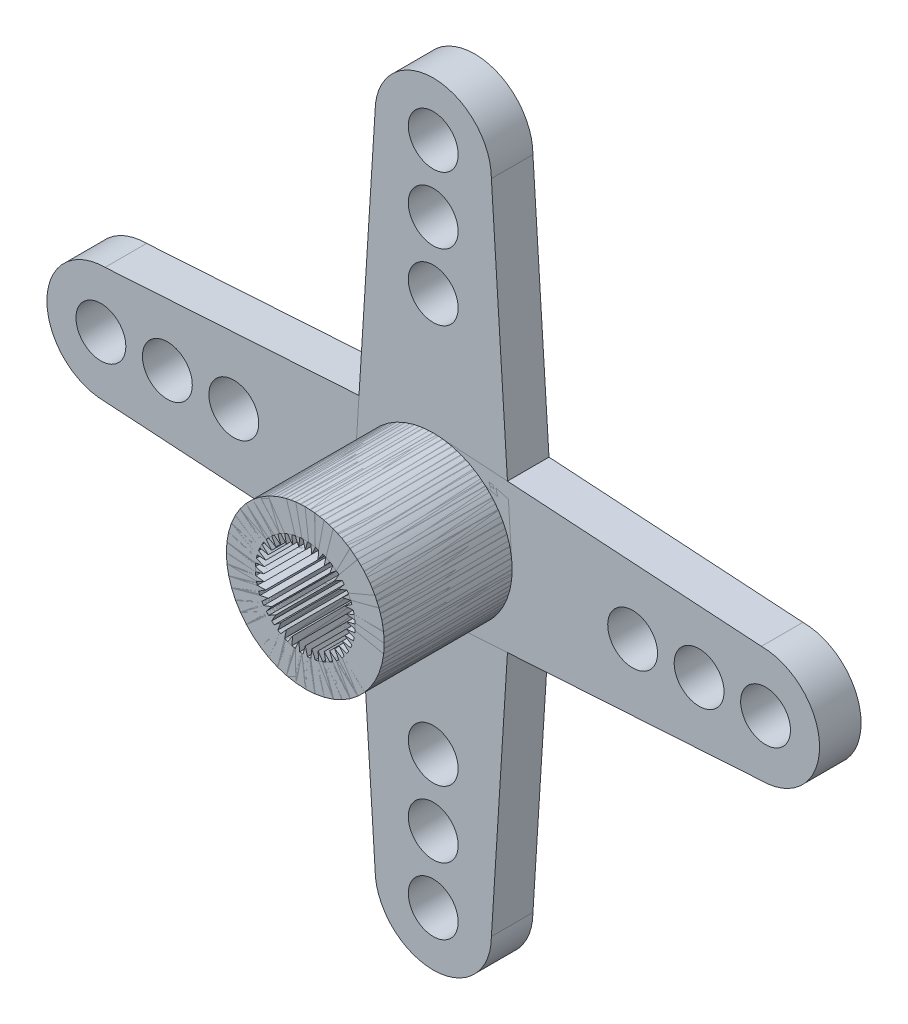
from build123d import *

# Parameters (mm, degrees)
SKETCH2_R           = 12.25
SKETCH2_R_2         = 1.594439563
BOSS_EXTRUDE1_DEPTH = 1
SKETCH3_R           = 1.5
CUT_EXTRUDE1_DEPTH  = 2
SKETCH4_R           = 4
SKETCH4_R_2         = 3
BOSS_EXTRUDE2_DEPTH = 5.7
BOSS_EXTRUDE3_START = 1
BOSS_EXTRUDE3_DEPTH = 5.7
SKETCH5_R           = 3
CUT_EXTRUDE2_DEPTH  = 0.5
SKETCH6_R           = 12.25
SKETCH6_R_2         = 4.25
CUT_EXTRUDE3_DEPTH  = 10
SKETCH7_R           = 4.25
SKETCH7_R_2         = 4
BOSS_EXTRUDE5_DEPTH = 5.7
SKETCH8_R           = 4.75
SKETCH8_R_2         = 4.25
BOSS_EXTRUDE6_DEPTH = 6.7
SKETCH9_R           = 4.75
SKETCH9_R_2         = 3
BOSS_EXTRUDE7_DEPTH = 3.5
SKETCH11_R          = 1.5
BOSS_EXTRUDE8_DEPTH = 2.5
CHAMFER3_SIZE       = 0.5
CIRPATTERN2_COUNT   = 4


with BuildPart() as part:
    # Sketch2 → Boss-Extrude1 (new body)
    with BuildSketch(Plane.XY):
        Circle(SKETCH2_R)
        with Locations((0, 8.25)):
            Circle(SKETCH2_R_2, mode=Mode.SUBTRACT)
        with Locations((0, -8.25)):
            Circle(SKETCH2_R_2, mode=Mode.SUBTRACT)
        with Locations((-8.25, 0)):
            Circle(SKETCH2_R_2, mode=Mode.SUBTRACT)
        with Locations((8.25, 0)):
            Circle(SKETCH2_R_2, mode=Mode.SUBTRACT)
    extrude(amount=BOSS_EXTRUDE1_DEPTH)

    # Sketch3 → Cut-Extrude1 (cut)
    with BuildSketch(Plane.XY.offset(1)):
        Circle(SKETCH3_R)
    extrude(amount=-CUT_EXTRUDE1_DEPTH, mode=Mode.SUBTRACT)

    # Sketch4 → Boss-Extrude2 (add)
    with BuildSketch(Plane.XY.offset(1)):
        Circle(SKETCH4_R)
        Circle(SKETCH4_R_2, mode=Mode.SUBTRACT)
    extrude(amount=BOSS_EXTRUDE2_DEPTH)

    # Sketch1 → Boss-Extrude3 (add)
    with BuildSketch(Plane.XY.offset(BOSS_EXTRUDE3_START)):
        with BuildLine():
            Line((-2.5, 0), (-2.996937116, 0.135528304))
            ThreePointArc((-2.996937116, 0.135528304), (-3, 0), (-2.996937116, -0.135528304))
            Line((-2.996937116, -0.135528304), (-2.5, 0))
        make_face()
        with BuildLine():
            Line((-2.469220853, 0.391086156), (-2.938838551, 0.602683972))
            ThreePointArc((-2.938838551, 0.602683972), (-2.963065023, 0.469303387), (-2.981241146, 0.33496452))
            Line((-2.981241146, 0.33496452), (-2.469220853, 0.391086156))
        make_face()
        with BuildLine():
            ThreePointArc((-2.808376064, 1.05499947), (-2.853169584, 0.927050875), (-2.892137153, 0.797209313))
            Line((-2.892137153, 0.797209313), (-2.37764132, 0.772542395))
            Line((-2.37764132, 0.772542395), (-2.808376064, 1.05499947))
        make_face()
        with BuildLine():
            ThreePointArc((-2.60876198, 1.481337548), (-2.673019591, 1.361971464), (-2.731819102, 1.239824339))
            Line((-2.731819102, 1.239824339), (-2.227516326, 1.13497622))
            Line((-2.227516326, 1.13497622), (-2.60876198, 1.481337548))
        make_face()
        with BuildLine():
            ThreePointArc((-2.344911528, 1.87120013), (-2.427050991, 1.763355746), (-2.504234604, 1.651910726))
            Line((-2.504234604, 1.651910726), (-2.022542492, 1.469463122))
            Line((-2.022542492, 1.469463122), (-2.344911528, 1.87120013))
        make_face()
        with BuildLine():
            ThreePointArc((-2.023321594, 2.214987523), (-2.121320362, 2.121320325), (-2.214987558, 2.023321555))
            Line((-2.214987558, 2.023321555), (-1.767766968, 1.767766938))
            Line((-1.767766968, 1.767766938), (-2.023321594, 2.214987523))
        make_face()
        with BuildLine():
            ThreePointArc((-1.651910742, 2.504234594), (-1.763355761, 2.42705098), (-1.871200145, 2.344911516))
            Line((-1.871200145, 2.344911516), (-1.469463134, 2.022542483))
            Line((-1.469463134, 2.022542483), (-1.651910742, 2.504234594))
        make_face()
        with BuildLine():
            ThreePointArc((-1.239824372, 2.731819088), (-1.361971495, 2.673019575), (-1.481337579, 2.608761963))
            Line((-1.481337579, 2.608761963), (-1.134976246, 2.227516312))
            Line((-1.134976246, 2.227516312), (-1.239824372, 2.731819088))
        make_face()
        with BuildLine():
            ThreePointArc((-0.797209399, 2.892137129), (-0.92705096, 2.853169556), (-1.054999554, 2.808376033))
            Line((-1.054999554, 2.808376033), (-0.772542467, 2.377641297))
            Line((-0.772542467, 2.377641297), (-0.797209399, 2.892137129))
        make_face()
        with BuildLine():
            ThreePointArc((-0.334964528, 2.981241145), (-0.469303394, 2.963065022), (-0.60268398, 2.938838549))
            Line((-0.60268398, 2.93883855), (-0.391086162, 2.469220852))
            Line((-0.391086162, 2.469220852), (-0.334964528, 2.981241145))
        make_face()
        with BuildLine():
            ThreePointArc((0.135528304, 2.996937116), (0, 3), (-0.135528304, 2.996937116))
            Line((-0.135528304, 2.996937116), (0, 2.5))
            Line((0, 2.5), (0.135528304, 2.996937116))
        make_face()
        with BuildLine():
            ThreePointArc((0.602683972, 2.938838551), (0.469303387, 2.963065023), (0.33496452, 2.981241146))
            Line((0.33496452, 2.981241146), (0.391086156, 2.469220853))
            Line((0.391086156, 2.469220853), (0.602683972, 2.938838551))
        make_face()
        with BuildLine():
            ThreePointArc((1.05499947, 2.808376064), (0.927050875, 2.853169584), (0.797209313, 2.892137153))
            Line((0.797209313, 2.892137153), (0.772542395, 2.37764132))
            Line((0.772542395, 2.37764132), (1.05499947, 2.808376064))
        make_face()
        with BuildLine():
            ThreePointArc((1.481337548, 2.60876198), (1.361971464, 2.673019591), (1.239824339, 2.731819102))
            Line((1.239824339, 2.731819102), (1.13497622, 2.227516326))
            Line((1.13497622, 2.227516326), (1.481337548, 2.60876198))
        make_face()
        with BuildLine():
            ThreePointArc((1.87120013, 2.344911528), (1.763355746, 2.427050991), (1.651910726, 2.504234604))
            Line((1.651910726, 2.504234604), (1.469463122, 2.022542492))
            Line((1.469463122, 2.022542492), (1.87120013, 2.344911528))
        make_face()
        with BuildLine():
            ThreePointArc((2.214987523, 2.023321594), (2.121320325, 2.121320362), (2.023321555, 2.214987558))
            Line((2.023321555, 2.214987558), (1.767766938, 1.767766968))
            Line((1.767766938, 1.767766968), (2.214987523, 2.023321594))
        make_face()
        with BuildLine():
            ThreePointArc((2.504234594, 1.651910742), (2.42705098, 1.763355761), (2.344911516, 1.871200144))
            Line((2.344911516, 1.871200145), (2.022542483, 1.469463134))
            Line((2.022542483, 1.469463134), (2.504234594, 1.651910742))
        make_face()
        with BuildLine():
            ThreePointArc((2.731819087, 1.239824371), (2.673019574, 1.361971495), (2.608761963, 1.481337578))
            Line((2.608761963, 1.481337579), (2.227516312, 1.134976246))
            Line((2.227516312, 1.134976246), (2.731819088, 1.239824371))
        make_face()
        with BuildLine():
            ThreePointArc((2.892137129, 0.797209399), (2.853169556, 0.92705096), (2.808376032, 1.054999554))
            Line((2.808376033, 1.054999554), (2.377641297, 0.772542467))
            Line((2.377641297, 0.772542467), (2.892137129, 0.797209399))
        make_face()
        with BuildLine():
            ThreePointArc((2.981241145, 0.334964528), (2.963065022, 0.469303394), (2.938838549, 0.60268398))
            Line((2.93883855, 0.60268398), (2.469220852, 0.391086162))
            Line((2.469220852, 0.391086162), (2.981241145, 0.334964528))
        make_face()
        with BuildLine():
            ThreePointArc((3, 0), (2.999234181, 0.067781455), (2.996937116, 0.135528304))
            Line((2.996937116, 0.135528304), (2.5, 0))
            Line((2.5, 0), (2.996937116, -0.135528304))
            ThreePointArc((2.996937116, -0.135528304), (2.999234181, -0.067781455), (3, 0))
        make_face()
        with BuildLine():
            ThreePointArc((2.938838551, -0.602683972), (2.963065023, -0.469303387), (2.981241146, -0.33496452))
            Line((2.981241146, -0.33496452), (2.469220853, -0.391086156))
            Line((2.469220853, -0.391086156), (2.938838551, -0.602683973))
        make_face()
        with BuildLine():
            Line((2.37764132, -0.772542396), (2.808376064, -1.05499947))
            ThreePointArc((2.808376064, -1.05499947), (2.853169584, -0.927050875), (2.892137153, -0.797209313))
            Line((2.892137153, -0.797209313), (2.37764132, -0.772542396))
        make_face()
        with BuildLine():
            Line((2.227516326, -1.13497622), (2.60876198, -1.481337548))
            ThreePointArc((2.60876198, -1.481337548), (2.67301959, -1.361971464), (2.731819102, -1.239824339))
            Line((2.731819102, -1.239824339), (2.227516326, -1.13497622))
        make_face()
        with BuildLine():
            Line((2.022542492, -1.469463122), (2.344911528, -1.87120013))
            ThreePointArc((2.344911528, -1.87120013), (2.427050991, -1.763355746), (2.504234604, -1.651910726))
            Line((2.504234604, -1.651910726), (2.022542492, -1.469463122))
        make_face()
        with BuildLine():
            Line((1.767766968, -1.767766938), (2.023321594, -2.214987523))
            ThreePointArc((2.023321594, -2.214987523), (2.121320362, -2.121320325), (2.214987558, -2.023321555))
            Line((2.214987558, -2.023321555), (1.767766968, -1.767766938))
        make_face()
        with BuildLine():
            Line((1.469463134, -2.022542483), (1.651910742, -2.504234594))
            ThreePointArc((1.651910742, -2.504234594), (1.763355761, -2.42705098), (1.871200144, -2.344911516))
            Line((1.871200145, -2.344911516), (1.469463134, -2.022542483))
        make_face()
        with BuildLine():
            Line((1.134976246, -2.227516312), (1.239824371, -2.731819088))
            ThreePointArc((1.239824371, -2.731819087), (1.361971495, -2.673019574), (1.481337578, -2.608761963))
            Line((1.481337579, -2.608761963), (1.134976246, -2.227516312))
        make_face()
        with BuildLine():
            Line((0.772542467, -2.377641297), (0.797209399, -2.892137129))
            ThreePointArc((0.797209399, -2.892137129), (0.92705096, -2.853169556), (1.054999554, -2.808376032))
            Line((1.054999554, -2.808376033), (0.772542467, -2.377641297))
        make_face()
        with BuildLine():
            Line((0.391086162, -2.469220852), (0.334964528, -2.981241145))
            ThreePointArc((0.334964528, -2.981241145), (0.469303394, -2.963065022), (0.60268398, -2.938838549))
            Line((0.60268398, -2.93883855), (0.391086162, -2.469220852))
        make_face()
        with BuildLine():
            Line((0, -2.5), (-0.135528304, -2.996937116))
            ThreePointArc((-0.135528304, -2.996937116), (0, -3), (0.135528304, -2.996937116))
            Line((0.135528304, -2.996937116), (0, -2.5))
        make_face()
        with BuildLine():
            Line((-0.391086156, -2.469220853), (-0.602683973, -2.938838551))
            ThreePointArc((-0.602683972, -2.938838551), (-0.469303387, -2.963065023), (-0.33496452, -2.981241146))
            Line((-0.33496452, -2.981241146), (-0.391086156, -2.469220853))
        make_face()
        with BuildLine():
            Line((-0.772542396, -2.37764132), (-1.05499947, -2.808376064))
            ThreePointArc((-1.05499947, -2.808376064), (-0.927050875, -2.853169584), (-0.797209313, -2.892137153))
            Line((-0.797209313, -2.892137153), (-0.772542396, -2.37764132))
        make_face()
        with BuildLine():
            Line((-1.13497622, -2.227516326), (-1.481337548, -2.60876198))
            ThreePointArc((-1.481337548, -2.60876198), (-1.361971464, -2.673019591), (-1.239824339, -2.731819102))
            Line((-1.239824339, -2.731819102), (-1.13497622, -2.227516326))
        make_face()
        with BuildLine():
            Line((-1.469463122, -2.022542492), (-1.87120013, -2.344911528))
            ThreePointArc((-1.87120013, -2.344911528), (-1.763355746, -2.427050991), (-1.651910726, -2.504234604))
            Line((-1.651910726, -2.504234604), (-1.469463122, -2.022542492))
        make_face()
        with BuildLine():
            Line((-1.767766938, -1.767766968), (-2.214987523, -2.023321594))
            ThreePointArc((-2.214987523, -2.023321594), (-2.121320325, -2.121320362), (-2.023321555, -2.214987558))
            Line((-2.023321555, -2.214987558), (-1.767766938, -1.767766968))
        make_face()
        with BuildLine():
            Line((-2.022542483, -1.469463134), (-2.504234594, -1.651910742))
            ThreePointArc((-2.504234594, -1.651910742), (-2.42705098, -1.763355761), (-2.344911516, -1.871200145))
            Line((-2.344911516, -1.871200145), (-2.022542483, -1.469463134))
        make_face()
        with BuildLine():
            Line((-2.227516312, -1.134976246), (-2.731819088, -1.239824372))
            ThreePointArc((-2.731819088, -1.239824372), (-2.673019575, -1.361971495), (-2.608761963, -1.481337579))
            Line((-2.608761963, -1.481337579), (-2.227516312, -1.134976246))
        make_face()
        with BuildLine():
            Line((-2.377641297, -0.772542467), (-2.892137129, -0.797209399))
            ThreePointArc((-2.892137129, -0.797209399), (-2.853169556, -0.92705096), (-2.808376033, -1.054999554))
            Line((-2.808376033, -1.054999554), (-2.377641297, -0.772542467))
        make_face()
        with BuildLine():
            Line((-2.469220852, -0.391086162), (-2.981241145, -0.334964528))
            ThreePointArc((-2.981241145, -0.334964528), (-2.963065022, -0.469303394), (-2.93883855, -0.60268398))
            Line((-2.93883855, -0.60268398), (-2.469220852, -0.391086162))
        make_face()
    extrude(amount=BOSS_EXTRUDE3_DEPTH)

    # Sketch5 → Cut-Extrude2 (cut)
    with BuildSketch(Plane(origin=(0, 0, 0), x_dir=(-1, 0, 0), z_dir=(0, 0, -1))):
        Circle(SKETCH5_R)
    extrude(amount=-CUT_EXTRUDE2_DEPTH, mode=Mode.SUBTRACT)

    # Sketch6 → Cut-Extrude3 (cut)
    with BuildSketch(Plane.XY.offset(1)):
        Circle(SKETCH6_R)
        Circle(SKETCH6_R_2, mode=Mode.SUBTRACT)
    extrude(amount=-CUT_EXTRUDE3_DEPTH, mode=Mode.SUBTRACT)

    # Sketch7 → Boss-Extrude5 (add)
    with BuildSketch(Plane.XY.offset(1)):
        Circle(SKETCH7_R)
        Circle(SKETCH7_R_2, mode=Mode.SUBTRACT)
    extrude(amount=BOSS_EXTRUDE5_DEPTH)

    # Sketch8 → Boss-Extrude6 (add)
    with BuildSketch(Plane(origin=(0, 0, 0), x_dir=(-1, 0, 0), z_dir=(0, 0, -1))):
        Circle(SKETCH8_R)
        Circle(SKETCH8_R_2, mode=Mode.SUBTRACT)
    extrude(amount=-BOSS_EXTRUDE6_DEPTH)

    # Sketch9 → Boss-Extrude7 (add)
    with BuildSketch(Plane(origin=(0, 0, 0), x_dir=(-1, 0, 0), z_dir=(0, 0, -1))):
        Circle(SKETCH9_R)
        Circle(SKETCH9_R_2, mode=Mode.SUBTRACT)
    extrude(amount=BOSS_EXTRUDE7_DEPTH)

    # Sketch11 → Boss-Extrude8 (add)
    with BuildSketch(Plane(origin=(0, 0, -3.5), x_dir=(-1, 0, 0), z_dir=(0, 0, -1))):
        with BuildLine():
            ThreePointArc((4.712097032, -0.598866901), (0, -4.75), (-4.712097032, -0.598866901))
            Line((-4.712097032, -0.598866901), (-3.5, -19.75))
            ThreePointArc((-3.5, -19.75), (0, -23.25), (3.5, -19.75))
            Line((3.5, -19.75), (4.712097032, -0.598866901))
        make_face()
        with Locations((0, -20)):
            Circle(SKETCH11_R, mode=Mode.SUBTRACT)
        with Locations((0, -16)):
            Circle(SKETCH11_R, mode=Mode.SUBTRACT)
        with Locations((0, -12)):
            Circle(SKETCH11_R, mode=Mode.SUBTRACT)
    extrude(amount=-BOSS_EXTRUDE8_DEPTH)

    # Chamfer3
    chamfer3_edges = [part.edges().sort_by_distance(p)[0] for p in [
        (3, 0, -3.5),
    ]]
    chamfer(chamfer3_edges, length=CHAMFER3_SIZE)


with BuildPart() as cirpattern2_1:
    # CirPattern2: pattern copy
    add(part.part.rotate(Axis((0, 0, 0), (0, 0, 1)), 1 * 360 / CIRPATTERN2_COUNT))


with BuildPart() as cirpattern2_2:
    # CirPattern2: pattern copy
    add(part.part.rotate(Axis((0, 0, 0), (0, 0, 1)), 2 * 360 / CIRPATTERN2_COUNT))


with BuildPart() as cirpattern2_3:
    # CirPattern2: pattern copy
    add(part.part.rotate(Axis((0, 0, 0), (0, 0, 1)), 3 * 360 / CIRPATTERN2_COUNT))


solid = Compound([part.part, cirpattern2_1.part, cirpattern2_2.part, cirpattern2_3.part])
